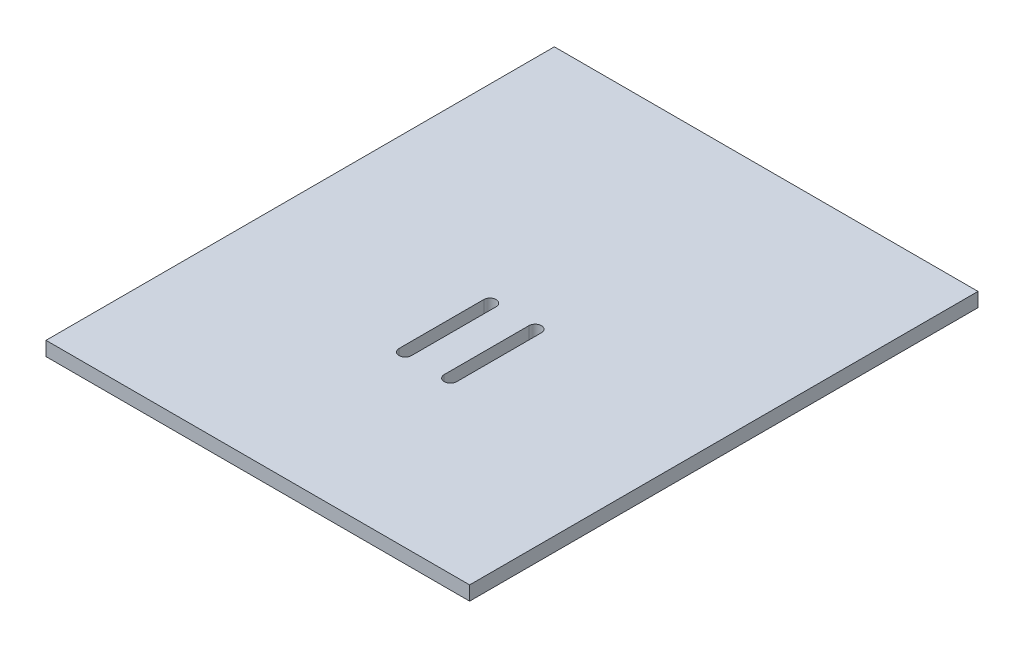
from build123d import *

# Parameters (mm, degrees)
SKETCH1_W           = 190.5
SKETCH1_H           = 228.6
BOSS_EXTRUDE1_DEPTH = 6.35
CUT_EXTRUDE1_REACH  = 8.35


with BuildPart() as part:
    # Sketch1 → Boss-Extrude1 (new body)
    with BuildSketch(Plane(origin=(0, 0, 0), x_dir=(1, 0, 0), z_dir=(0, 1, 0))):
        Rectangle(SKETCH1_W, SKETCH1_H)
    extrude(amount=BOSS_EXTRUDE1_DEPTH)

    # Sketch2 → Cut-Extrude1 (cut, up to next)
    with BuildSketch(Plane(origin=(0, 6.35, 0), x_dir=(1, 0, 0), z_dir=(0, 1, 0)), mode=Mode.PRIVATE) as cut_extrude1_sk1:
        with BuildLine():
            Line((-7.112, 0), (-7.112, -38.1))
            ThreePointArc((-7.112, -38.1), (-9.906, -40.894), (-12.7, -38.1))
            Line((-12.7, -38.1), (-12.7, 0))
            ThreePointArc((-12.7, 0), (-9.906, 2.794), (-7.112, 0))
        make_face()
    cut_extrude1_tool1 = extrude(cut_extrude1_sk1.sketch, amount=-CUT_EXTRUDE1_REACH, mode=Mode.PRIVATE) & part.part
    add(cut_extrude1_tool1.solids().sort_by_distance((-9.906, 6.35, 19.05))[0], mode=Mode.SUBTRACT)
    # Sketch2 → Cut-Extrude1 (cut, up to next)
    with BuildSketch(Plane(origin=(0, 6.35, 0), x_dir=(1, 0, 0), z_dir=(0, 1, 0)), mode=Mode.PRIVATE) as cut_extrude1_sk2:
        with BuildLine():
            Line((13.208, 0), (13.208, -38.1))
            ThreePointArc((13.208, -38.1), (10.414, -40.894), (7.62, -38.1))
            Line((7.62, -38.1), (7.62, 0))
            ThreePointArc((7.62, 0), (10.414, 2.794), (13.208, 0))
        make_face()
    cut_extrude1_tool2 = extrude(cut_extrude1_sk2.sketch, amount=-CUT_EXTRUDE1_REACH, mode=Mode.PRIVATE) & part.part
    add(cut_extrude1_tool2.solids().sort_by_distance((10.414, 6.35, 19.05))[0], mode=Mode.SUBTRACT)


solid = part.part
